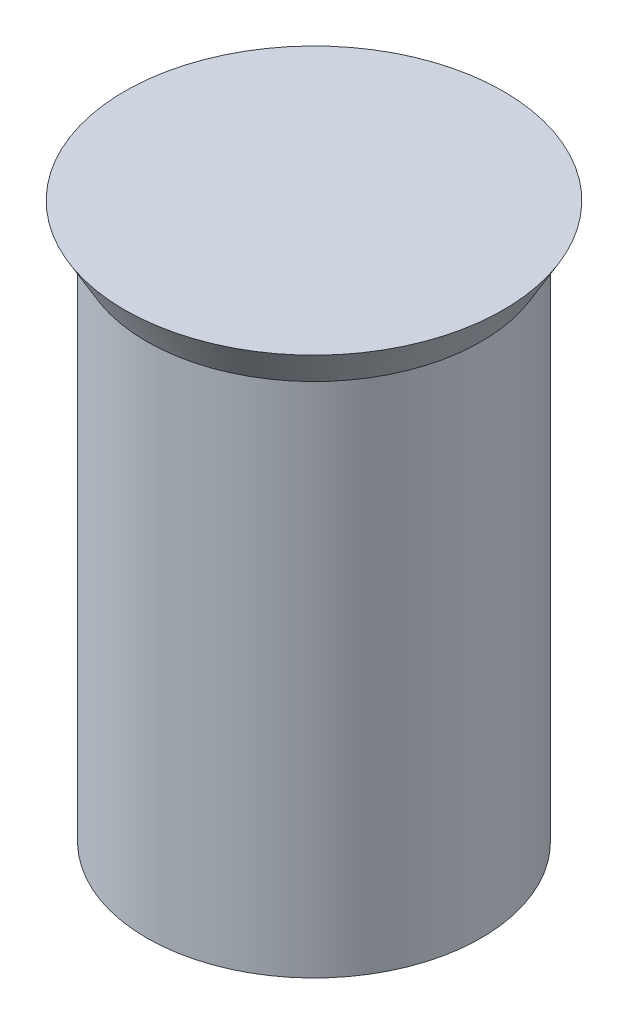
from build123d import *


with BuildPart() as part:
    # Sketch1 → Revolve1 (revolve)
    with BuildSketch(Plane(origin=(0, 0, 0), x_dir=(0, 0, -1), z_dir=(1, 0, 0))):
        Polygon((0, 0), (1.625, 0), (1.435, -0.3302), (1.435, -4.7625), (0, -4.7625), align=None)
    revolve(axis=Axis((0, 0, 0), (0, -1, 0)))


solid = part.part
